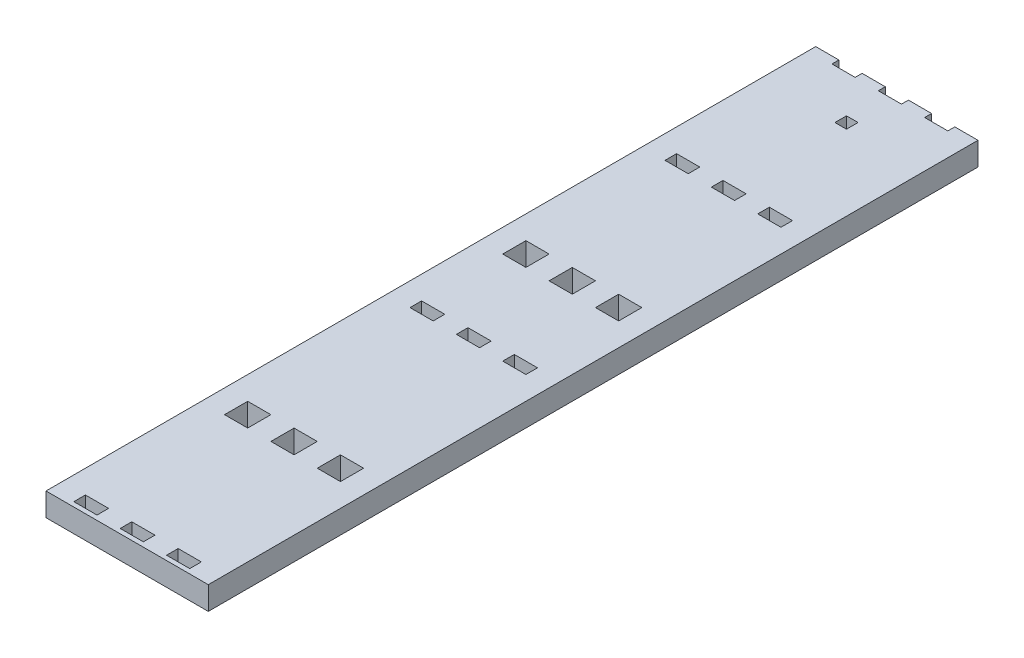
from build123d import *

# Parameters (mm, degrees)
ESQUISSE1_W                = 70
ESQUISSE1_H                = 332
BOSS_EXTRU_1_DEPTH         = 10
ESQUISSE2_W                = 10
ESQUISSE2_H                = 10
ESQUISSE2_H_2              = 5
ENL_V_MAT_EXTRU_1_DEPTH    = 10
R_P_TITION_LIN_AIRE1_COUNT = 3
R_P_TITION_LIN_AIRE1_PITCH = 20
ESQUISSE4_W                = 10
ESQUISSE4_H                = 5
ESQUISSE4_H_2              = 3
BOSS_EXTRU_2_DEPTH         = 10
R_P_TITION_LIN_AIRE2_COUNT = 4
R_P_TITION_LIN_AIRE2_PITCH = 20
ESQUISSE12_W               = 10
ESQUISSE12_H               = 5
ENL_V_MAT_EXTRU_7_DEPTH    = 10
R_P_TITION_LIN_AIRE5_COUNT = 3
R_P_TITION_LIN_AIRE5_PITCH = 20
ESQUISSE14_W               = 70
ESQUISSE14_H               = 2
BOSS_EXTRU_4_DEPTH         = 10
ESQUISSE17_W               = 10
ESQUISSE17_H               = 10
ENL_V_MAT_EXTRU_10_DEPTH   = 10
ESQUISSE18_W               = 10
ESQUISSE18_H               = 10
ENL_V_MAT_EXTRU_11_DEPTH   = 10
ESQUISSE19_W               = 5
ESQUISSE19_H               = 5
ENL_V_MAT_EXTRU_12_DEPTH   = 10


with BuildPart() as part:
    # Esquisse1 → Boss.-Extru.1 (new body)
    with BuildSketch(Plane(origin=(0, 0, 0), x_dir=(1, 0, 0), z_dir=(0, 1, 0))):
        with Locations((-7.984615385, -121.393323657)):
            Rectangle(ESQUISSE1_W, ESQUISSE1_H)
    extrude(amount=BOSS_EXTRU_1_DEPTH)

    # Esquisse2 → Enlèv. mat.-Extru.1 (cut)
    with BuildSketch(Plane(origin=(0, 10, 0), x_dir=(1, 0, 0), z_dir=(0, 1, 0))):
        with Locations((-27.984615385, -222.393323657)):
            Rectangle(ESQUISSE2_W, ESQUISSE2_H)
        with Locations((-27.984615385, -102.393323657)):
            Rectangle(ESQUISSE2_W, ESQUISSE2_H)
        with Locations((-27.984615385, -144.893323657)):
            Rectangle(ESQUISSE2_W, ESQUISSE2_H_2)
    enl_v_mat_extru_1 = extrude(amount=-ENL_V_MAT_EXTRU_1_DEPTH, mode=Mode.SUBTRACT)

    # Répétition linéaire1: Enlèv. mat.-Extru.1 ×3
    with Locations(*[(i * R_P_TITION_LIN_AIRE1_PITCH, 0, 0) for i in range(1, R_P_TITION_LIN_AIRE1_COUNT)]):
        add(enl_v_mat_extru_1, mode=Mode.SUBTRACT)

    # Esquisse4 → Boss.-Extru.2 (add)
    with BuildSketch(Plane(origin=(0, 10, 0), x_dir=(1, 0, 0), z_dir=(0, 1, 0))):
        with Locations((-37.984615385, -289.893323657)):
            Rectangle(ESQUISSE4_W, ESQUISSE4_H)
        with Locations((-37.984615385, 46.106676343)):
            Rectangle(ESQUISSE4_W, ESQUISSE4_H_2)
    boss_extru_2 = extrude(amount=-BOSS_EXTRU_2_DEPTH)

    # Répétition linéaire2: Boss.-Extru.2 ×4
    with Locations(*[(i * R_P_TITION_LIN_AIRE2_PITCH, 0, 0) for i in range(1, R_P_TITION_LIN_AIRE2_COUNT)]):
        add(boss_extru_2)

    # Esquisse12 → Enlèv. mat.-Extru.7 (cut)
    with BuildSketch(Plane(origin=(0, 10, 0), x_dir=(1, 0, 0), z_dir=(0, 1, 0))):
        with Locations((-27.984615385, -34.893323657)):
            Rectangle(ESQUISSE12_W, ESQUISSE12_H)
    enl_v_mat_extru_7 = extrude(amount=-ENL_V_MAT_EXTRU_7_DEPTH, mode=Mode.SUBTRACT)

    # Répétition linéaire5: Enlèv. mat.-Extru.7 ×3
    with Locations(*[(i * R_P_TITION_LIN_AIRE5_PITCH, 0, 0) for i in range(1, R_P_TITION_LIN_AIRE5_COUNT)]):
        add(enl_v_mat_extru_7, mode=Mode.SUBTRACT)

    # Esquisse14 → Boss.-Extru.4 (add)
    with BuildSketch(Plane(origin=(0, 10, 0), x_dir=(1, 0, 0), z_dir=(0, 1, 0))):
        with Locations((-7.984615385, -293.393323657)):
            Rectangle(ESQUISSE14_W, ESQUISSE14_H)
    extrude(amount=-BOSS_EXTRU_4_DEPTH)

    # Esquisse17 → Enlèv. mat.-Extru.10 (cut)
    with BuildSketch(Plane(origin=(0, 0, -44.606676343), x_dir=(-1, 0, 0), z_dir=(0, 0, -1))):
        with Locations((27.984615385, 5)):
            Rectangle(ESQUISSE17_W, ESQUISSE17_H)
        with Locations((7.984615385, 5)):
            Rectangle(ESQUISSE17_W, ESQUISSE17_H)
        with Locations((-12.015384615, 5)):
            Rectangle(ESQUISSE17_W, ESQUISSE17_H)
    extrude(amount=-ENL_V_MAT_EXTRU_10_DEPTH, mode=Mode.SUBTRACT)

    # Esquisse18 → Enlèv. mat.-Extru.11 (cut)
    with BuildSketch(Plane(origin=(0, 0, -47.606676343), x_dir=(-1, 0, 0), z_dir=(0, 0, -1))):
        with Locations((37.984615385, 5)):
            Rectangle(ESQUISSE18_W, ESQUISSE18_H)
        with Locations((17.984615385, 5)):
            Rectangle(ESQUISSE18_W, ESQUISSE18_H)
        with Locations((-2.015384615, 5)):
            Rectangle(ESQUISSE18_W, ESQUISSE18_H)
        with Locations((-22.015384615, 5)):
            Rectangle(ESQUISSE18_W, ESQUISSE18_H)
    extrude(amount=-ENL_V_MAT_EXTRU_11_DEPTH, mode=Mode.SUBTRACT)

    # Esquisse19 → Enlèv. mat.-Extru.12 (cut)
    with BuildSketch(Plane(origin=(0, 10, 0), x_dir=(1, 0, 0), z_dir=(0, 1, 0))):
        with Locations((-7.984615385, 15.876676343)):
            Rectangle(ESQUISSE19_W, ESQUISSE19_H)
    extrude(amount=-ENL_V_MAT_EXTRU_12_DEPTH, mode=Mode.SUBTRACT)


solid = part.part
